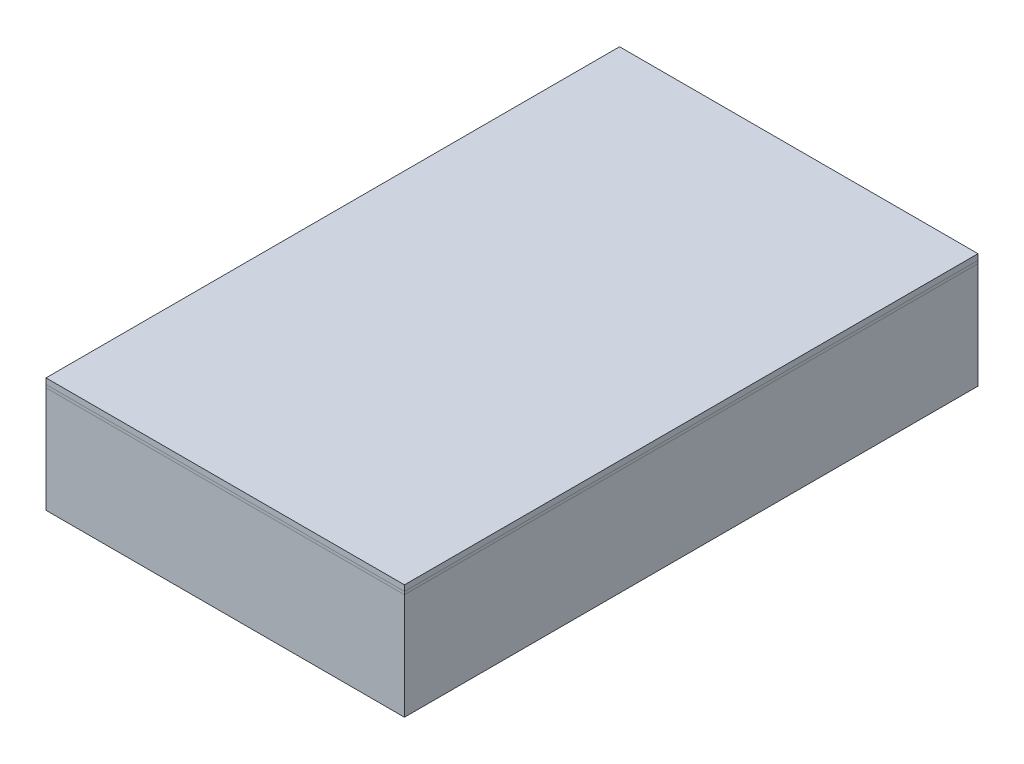
from build123d import *

# Parameters (mm, degrees)
SKETCH1_W           = 1.25
SKETCH1_H           = 2
BOSS_EXTRUDE1_DEPTH = 0.37
SKETCH2_W           = 1.25
SKETCH2_H           = 2
BOSS_EXTRUDE2_DEPTH = 0.01
SKETCH3_W           = 1.25
SKETCH3_H           = 2
BOSS_EXTRUDE3_DEPTH = 0.02


with BuildPart() as part:
    # Sketch1 → Boss-Extrude1 (new body)
    with BuildSketch(Plane(origin=(0, 0, 0), x_dir=(1, 0, 0), z_dir=(0, 1, 0))):
        Rectangle(SKETCH1_W, SKETCH1_H)
    extrude(amount=BOSS_EXTRUDE1_DEPTH)


with BuildPart() as body_2:
    # Sketch2 → Boss-Extrude2 (new body)
    with BuildSketch(Plane(origin=(0, 0.37, 0), x_dir=(1, 0, 0), z_dir=(0, 1, 0))):
        Rectangle(SKETCH2_W, SKETCH2_H)
    extrude(amount=BOSS_EXTRUDE2_DEPTH)


with BuildPart() as body_3:
    # Sketch3 → Boss-Extrude3 (new body)
    with BuildSketch(Plane(origin=(0, 0.38, 0), x_dir=(1, 0, 0), z_dir=(0, 1, 0))):
        Rectangle(SKETCH3_W, SKETCH3_H)
    extrude(amount=BOSS_EXTRUDE3_DEPTH)


solid = Compound([part.part, body_2.part, body_3.part])
